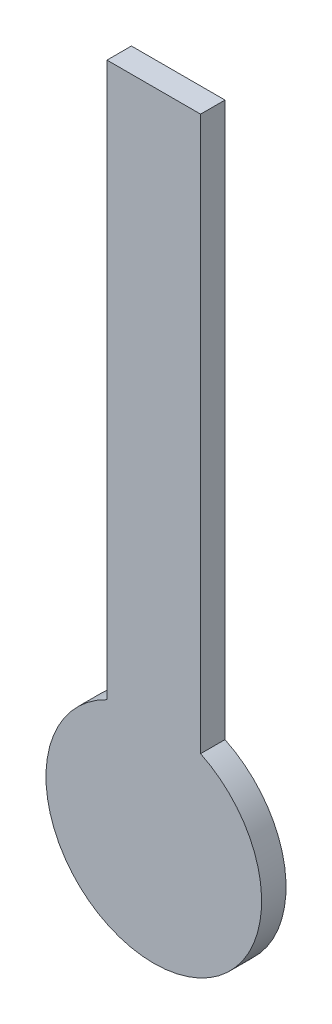
from build123d import *

# Parameters (mm, degrees)
BOSS_EXTRUDE1_DEPTH = 3


with BuildPart() as part:
    # Sketch1 → Boss-Extrude1 (new body)
    with BuildSketch(Plane.XY):
        with BuildLine():
            Line((-5.75, 11.937336386), (-5.75, 80))
            Line((-5.75, 80), (5.75, 80))
            Line((5.75, 80), (5.75, 11.937336386))
            ThreePointArc((5.75, 11.937336386), (0, -13.25), (-5.75, 11.937336386))
        make_face()
    extrude(amount=BOSS_EXTRUDE1_DEPTH)


solid = part.part
